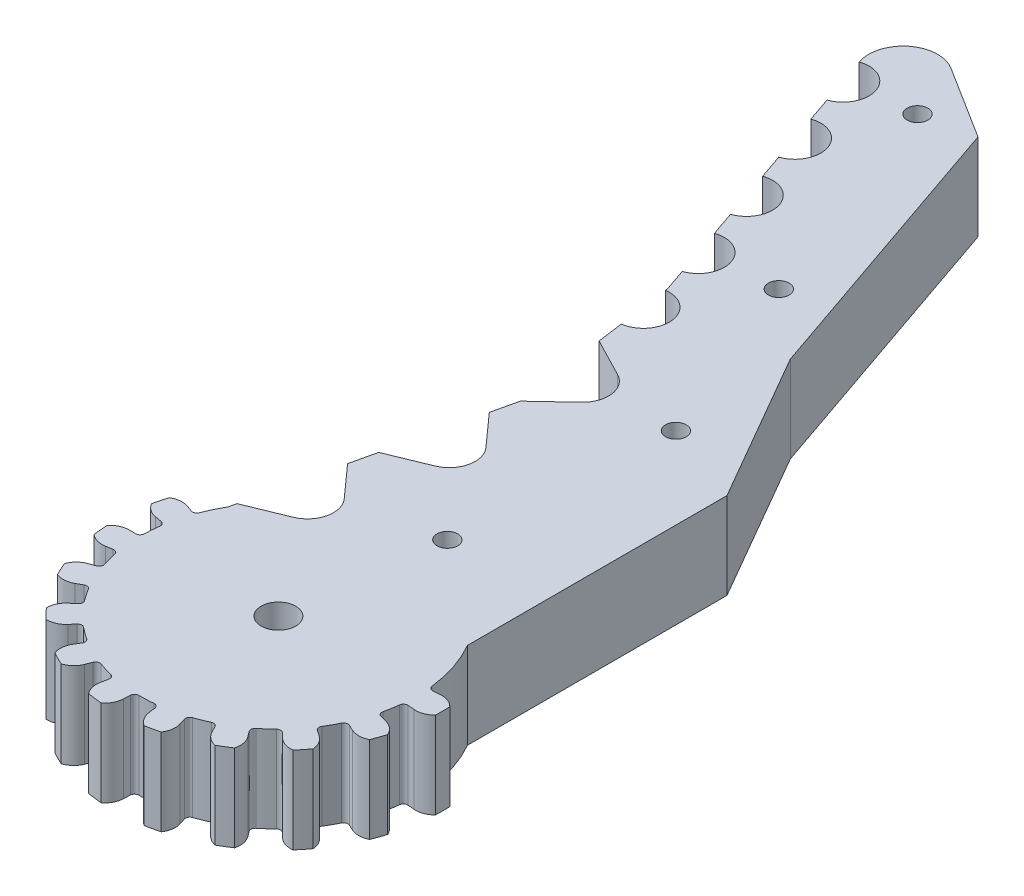
from build123d import *

# Parameters (mm, degrees)
SKETCH1_R                = 16
BOSS_EXTRUDE1_DEPTH      = 10
CUT_EXTRUDE1_DEPTH       = 10
BOSS_EXTRUDE2_DEPTH      = 10
FILLET1_R                = 0.5
CIRPATTERN1_COUNT        = 19
CIRPATTERN1_ANGLE        = 350
FILLET1_OF_CIRPATTERN1_R = 0.5
SKETCH4_R                = 2
CUT_EXTRUDE2_DEPTH       = 11
SKETCH5_R                = 1.2
CUT_EXTRUDE3_DEPTH       = 11


with BuildPart() as part:
    # Sketch1 → Boss-Extrude1 (new body)
    with BuildSketch(Plane(origin=(0, 0, 0), x_dir=(1, 0, 0), z_dir=(0, 1, 0))):
        with BuildLine():
            Line((162.614680299, 55.320508076), (165.373914051, 35.511756749))
            Line((165.373914051, 35.511756749), (159.055986536, 8))
            ThreePointArc((159.055986536, 8), (172.912392996, 16), (186.768799457, 8))
            Line((186.768799457, 8), (186.768799457, 38))
            Line((186.768799457, 38), (176.768799457, 55.320508076))
            Line((176.768799457, 55.320508076), (165.373914051, 88.413658222))
            Line((165.373914051, 88.413658222), (156.912392996, 93.743072959))
            ThreePointArc((156.912392996, 93.743072959), (152.296156749, 93.493334083), (150.998552799, 89.056191919))
            Line((150.998552799, 89.056191919), (162.614680299, 55.320508076))
        make_face()
        with Locations((172.912392996, 0)):
            Circle(SKETCH1_R)
    extrude(amount=BOSS_EXTRUDE1_DEPTH)

    # Sketch2 → Cut-Extrude1 (cut)
    with BuildSketch(Plane(origin=(0, 10, 0), x_dir=(1, 0, 0), z_dir=(0, 1, 0))):
        with BuildLine():
            Line((150.998552799, 89.056191919), (152.951961726, 83.383080466))
            ThreePointArc((152.951961726, 83.383080466), (154.811812989, 87.196340656), (150.998552799, 89.056191919))
        make_face()
        with BuildLine():
            Line((153.928666189, 80.546524739), (155.882075116, 74.873413285))
            ThreePointArc((155.882075116, 74.873413285), (157.741926379, 78.686673476), (153.928666189, 80.546524739))
        make_face()
        with BuildLine():
            Line((156.858779579, 72.036857559), (158.812188506, 66.363746105))
            ThreePointArc((158.812188506, 66.363746105), (160.672039769, 70.177006295), (156.858779579, 72.036857559))
        make_face()
        with BuildLine():
            Line((159.788892969, 63.527190378), (161.742301896, 57.854078925))
            ThreePointArc((161.742301896, 57.854078925), (163.602153159, 61.667339115), (159.788892969, 63.527190378))
        make_face()
        with BuildLine():
            Line((162.659719683, 54.997166876), (163.487489808, 49.054541478))
            ThreePointArc((163.487489808, 49.054541478), (166.044917445, 52.43973924), (162.659719683, 54.997166876))
        make_face()
        with BuildLine():
            Line((163.901374871, 46.083228779), (165.373914051, 35.511756749))
            Line((165.373914051, 35.511756749), (169.018329151, 38.934948035))
            ThreePointArc((169.018329151, 38.934948035), (169.935727078, 41.535482158), (168.342564959, 43.786311148))
            Line((168.342564959, 43.786311148), (163.901374871, 46.083228779))
        make_face()
        with BuildLine():
            Line((168.037228767, 28.862370748), (164.702457837, 32.587864386))
            Line((164.702457837, 32.587864386), (162.314311904, 22.18855388))
            Line((162.314311904, 22.18855388), (166.940336365, 24.085893514))
            ThreePointArc((166.940336365, 24.085893514), (168.725824948, 26.190051977), (168.037228767, 28.862370748))
        make_face()
        with BuildLine():
            Line((164.977626621, 15.539167879), (161.642855691, 19.264661516))
            Line((161.642855691, 19.264661516), (159.254709758, 8.86535101))
            Line((159.254709758, 8.86535101), (163.880734219, 10.762690644))
            ThreePointArc((163.880734219, 10.762690644), (165.666222802, 12.866849107), (164.977626621, 15.539167879))
        make_face()
    extrude(amount=-CUT_EXTRUDE1_DEPTH, mode=Mode.SUBTRACT)

    # Sketch3 → Boss-Extrude2 (add)
    with BuildSketch(Plane(origin=(0, 10, 0), x_dir=(1, 0, 0), z_dir=(0, 1, 0))):
        with BuildLine():
            Line((190.096751538, 1.503436562), (188.851508166, 1.394491884))
            ThreePointArc((188.851508166, 1.394491884), (188.912392996, 0), (188.851508166, -1.394491884))
            Line((188.851508166, -1.394491884), (190.096751538, -1.503436562))
            ThreePointArc((190.096751538, -1.503436562), (191.072085254, -1.370072078), (191.894309206, -0.82876836))
            ThreePointArc((191.894309206, -0.82876836), (191.912392996, 0), (191.894309206, 0.82876836))
            ThreePointArc((191.894309206, 0.82876836), (191.072085254, 1.370072078), (190.096751538, 1.503436562))
        make_face()
    boss_extrude2 = extrude(amount=-BOSS_EXTRUDE2_DEPTH)

    # Fillet1
    fillet1_edges = [part.edges().sort_by_distance(p)[0] for p in [
        (188.851508166, 5, 1.394491884),
        (188.851508166, 5, -1.394491884),
    ]]
    fillet(fillet1_edges, radius=FILLET1_R)

    # CirPattern1: Boss-Extrude2 ×19 about axis, 8 skipped
    cirpattern1_axis = Axis((172.912392996, 0, 0), (0, -1, 0))
    add([boss_extrude2.rotate(cirpattern1_axis, i * CIRPATTERN1_ANGLE / (CIRPATTERN1_COUNT - 1)) for i in range(1, CIRPATTERN1_COUNT) if i not in (11, 12, 13, 14, 15, 16, 17, 18)])

    # Fillet1 of CirPattern1
    fillet1_of_cirpattern1_edges = [part.edges().sort_by_distance(p)[0] for p in [
        (187.478200052, 5, 6.620971592),
        (188.406632365, 5, 3.991058305),
        (184.443362059, 5, 11.092193312),
        (186.194319884, 5, 8.921346207),
        (180.093179879, 5, 14.298122245),
        (182.466930463, 5, 12.833971084),
        (174.923881264, 5, 15.873056257),
        (177.649649531, 5, 15.282617594),
        (169.52513104, 5, 15.637341732),
        (172.291987056, 5, 15.98796724),
        (164.512767711, 5, 13.617866759),
        (167.005094639, 5, 14.869560388),
        (160.458554405, 5, 10.044993995),
        (162.392051099, 5, 12.054974341),
        (157.824957537, 5, 5.326283064),
        (158.979068931, 5, 7.865270529),
        (156.912392996, 5, 0),
        (157.155468948, 5, 2.778370843),
        (157.824957537, 5, -5.326283064),
        (157.129270235, 5, -2.625459183),
    ]]
    fillet(fillet1_of_cirpattern1_edges, radius=FILLET1_OF_CIRPATTERN1_R)

    # Sketch4 → Cut-Extrude2 (cut, through all)
    with BuildSketch(Plane(origin=(0, 10, 0), x_dir=(1, 0, 0), z_dir=(0, 1, 0))):
        with Locations((172.912392996, 0)):
            Circle(SKETCH4_R)
    extrude(amount=-CUT_EXTRUDE2_DEPTH, mode=Mode.SUBTRACT)

    # Sketch5 → Cut-Extrude3 (cut, through all)
    with BuildSketch(Plane(origin=(0, 10, 0), x_dir=(1, 0, 0), z_dir=(0, 1, 0))):
        with Locations((169.092781716, 61.667339115)):
            Circle(SKETCH5_R)
        with Locations((177.33165748, 41.535482158)):
            Circle(SKETCH5_R)
        with Locations((175.039520306, 17.401914698)):
            Circle(SKETCH5_R)
        with Locations((159.593070103, 87.196340656)):
            Circle(SKETCH5_R)
    extrude(amount=-CUT_EXTRUDE3_DEPTH, mode=Mode.SUBTRACT)


solid = part.part
